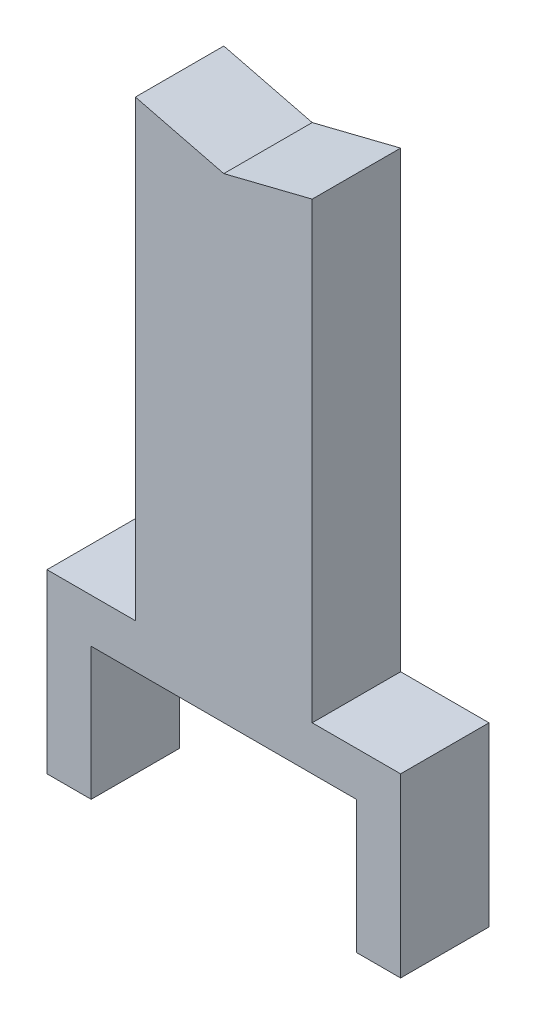
from build123d import *

# Parameters (mm, degrees)
BOSS_EXTRUDE1_DEPTH = 25.4


with BuildPart() as part:
    # Sketch1 → Boss-Extrude1 (new body, symmetric)
    with BuildSketch(Plane.XY):
        Polygon((0, 349.504), (-50.8, 362.204), (-50.8, 101.6), (-101.6, 101.6), (-101.6, 0), (-76.2, 0), (-76.2, 76.2), (0, 76.2), (76.2, 76.2), (76.2, 0), (101.6, 0), (101.6, 101.6), (50.8, 101.6), (50.8, 362.204), align=None)
    extrude(amount=BOSS_EXTRUDE1_DEPTH, both=True)


solid = part.part
